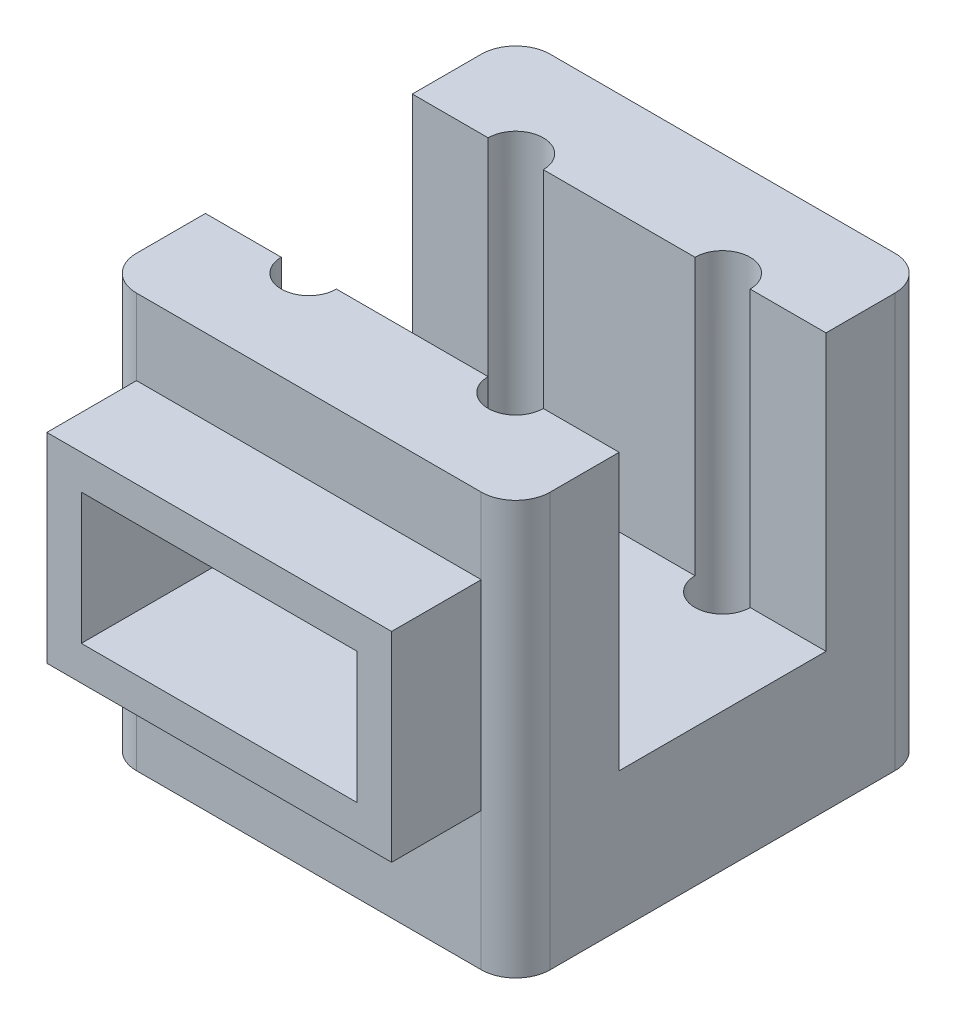
from build123d import *

# Parameters (mm, degrees)
SKETCH1_W           = 60
SKETCH1_H           = 60
SKETCH1_R           = 2
BOSS_EXTRUDE1_DEPTH = 60
SKETCH2_R           = 4
CUT_EXTRUDE1_DEPTH  = 50
FILLET1_R           = 5
SKETCH3_W           = 30
SKETCH3_H           = 40
CUT_EXTRUDE2_DEPTH  = 61
SKETCH4_W           = 40
SKETCH4_H           = 19
CUT_EXTRUDE3_DEPTH  = 30
SKETCH5_W           = 50
SKETCH5_H           = 29
SKETCH5_W_2         = 40
SKETCH5_H_2         = 19
BOSS_EXTRUDE3_DEPTH = 13
SKETCH6_R           = 10
CUT_EXTRUDE4_DEPTH  = 10


with BuildPart() as part:
    # Sketch1 → Boss-Extrude1 (new body)
    with BuildSketch(Plane(origin=(0, 0, 0), x_dir=(1, 0, 0), z_dir=(0, 1, 0))):
        Rectangle(SKETCH1_W, SKETCH1_H)
        with Locations((-15, 15)):
            Circle(SKETCH1_R, mode=Mode.SUBTRACT)
        with Locations((15, 15)):
            Circle(SKETCH1_R, mode=Mode.SUBTRACT)
        with Locations((15, -15)):
            Circle(SKETCH1_R, mode=Mode.SUBTRACT)
        with Locations((-15, -15)):
            Circle(SKETCH1_R, mode=Mode.SUBTRACT)
    extrude(amount=BOSS_EXTRUDE1_DEPTH)

    # Sketch2 → Cut-Extrude1 (cut)
    with BuildSketch(Plane(origin=(0, 60, 0), x_dir=(1, 0, 0), z_dir=(0, 1, 0))):
        with Locations((-15, 15)):
            Circle(SKETCH2_R)
        with Locations((15, 15)):
            Circle(SKETCH2_R)
        with Locations((15, -15)):
            Circle(SKETCH2_R)
        with Locations((-15, -15)):
            Circle(SKETCH2_R)
    extrude(amount=-CUT_EXTRUDE1_DEPTH, mode=Mode.SUBTRACT)

    # Fillet1
    fillet1_edges = [part.edges().sort_by_distance(p)[0] for p in [
        (30, 30, 30),
        (-30, 30, 30),
        (-30, 30, -30),
        (30, 30, -30),
    ]]
    fillet(fillet1_edges, radius=FILLET1_R)

    # Sketch3 → Cut-Extrude2 (cut, through all)
    with BuildSketch(Plane(origin=(30, 0, 0), x_dir=(0, 0, -1), z_dir=(1, 0, 0))):
        with Locations((0, 40)):
            Rectangle(SKETCH3_W, SKETCH3_H)
    extrude(amount=-CUT_EXTRUDE2_DEPTH, mode=Mode.SUBTRACT)

    # Sketch4 → Cut-Extrude3 (cut)
    with BuildSketch(Plane.XY.offset(30)):
        with Locations((0, 34.5)):
            Rectangle(SKETCH4_W, SKETCH4_H)
    extrude(amount=-CUT_EXTRUDE3_DEPTH, mode=Mode.SUBTRACT)

    # Sketch5 → Boss-Extrude3 (add)
    with BuildSketch(Plane.XY.offset(30)):
        with Locations((0, 34.5)):
            Rectangle(SKETCH5_W, SKETCH5_H)
        with Locations((0, 34.5)):
            Rectangle(SKETCH5_W_2, SKETCH5_H_2, mode=Mode.SUBTRACT)
    extrude(amount=BOSS_EXTRUDE3_DEPTH)

    # Sketch6 → Cut-Extrude4 (cut)
    with BuildSketch(Plane(origin=(0, 0, -30), x_dir=(-1, 0, 0), z_dir=(0, 0, -1))):
        with Locations((0, 40)):
            Circle(SKETCH6_R)
    extrude(amount=-CUT_EXTRUDE4_DEPTH, mode=Mode.SUBTRACT)


solid = part.part
